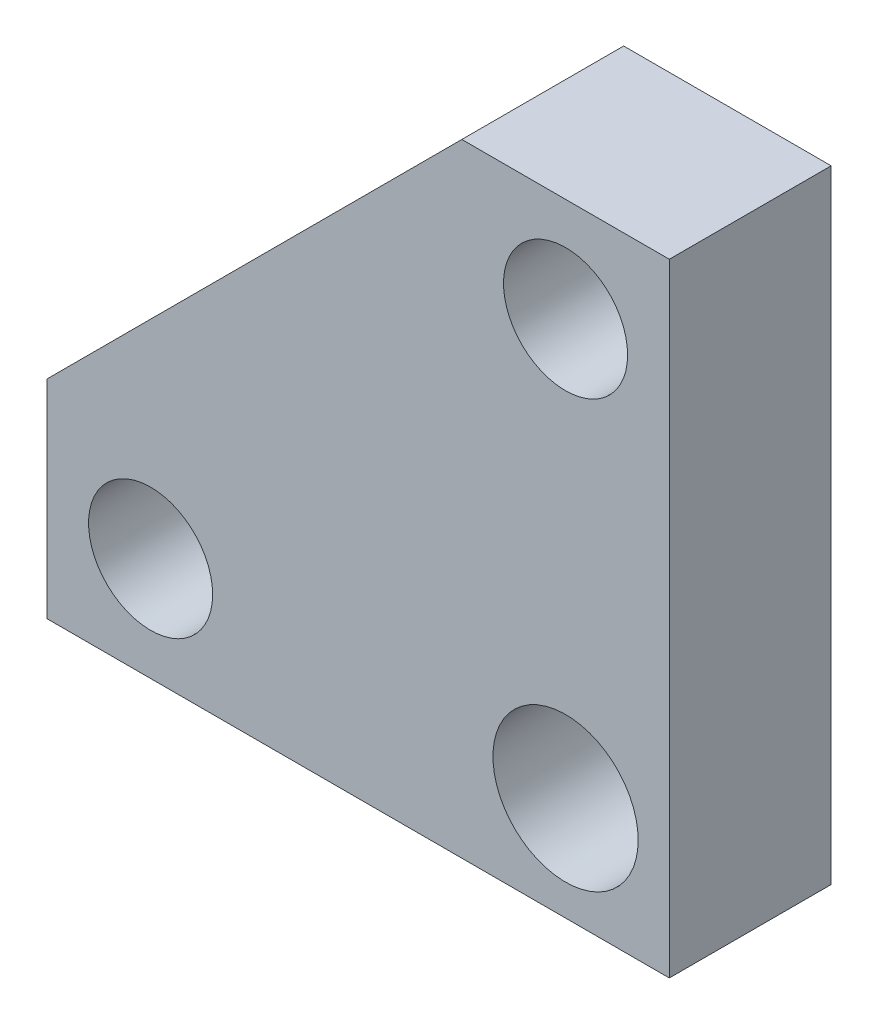
from build123d import *

# Parameters (mm, degrees)
ESQUISSE1_R      = 2.99
ESQUISSE1_R_2    = 3.5
EXTRUSION1_DEPTH = 3.9


with BuildPart() as part:
    # Esquisse1 → Extrusion1 (new body, symmetric)
    with BuildSketch(Plane.XY):
        Polygon((0, 0), (0, 30), (-10, 30), (-30, 10), (-30, 0), align=None)
        with Locations((-5, 25)):
            Circle(ESQUISSE1_R, mode=Mode.SUBTRACT)
        with Locations((-25, 5)):
            Circle(ESQUISSE1_R, mode=Mode.SUBTRACT)
        with Locations((-5, 5)):
            Circle(ESQUISSE1_R_2, mode=Mode.SUBTRACT)
    extrude(amount=EXTRUSION1_DEPTH, both=True)


solid = part.part
